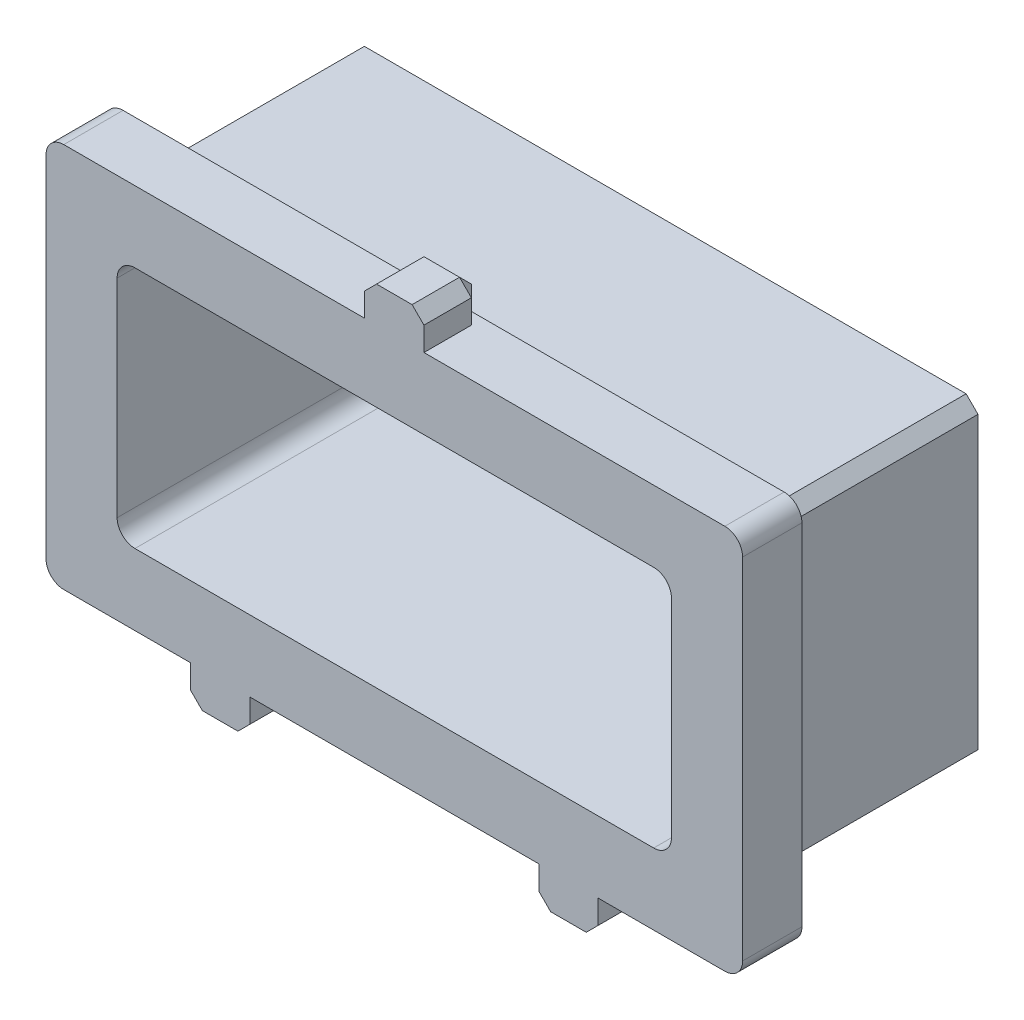
from build123d import *

# Parameters (mm, degrees)
SKETCH1_W           = 13.3985
SKETCH1_H           = 6.731
SKETCH1_W_2         = 11.8745
SKETCH1_H_2         = 5.207
EXTRUDE_THIN1_DEPTH = 5.8039
SKETCH2_W           = 14.9225
SKETCH2_H           = 8.255
SKETCH2_W_2         = 13.3985
SKETCH2_H_2         = 6.731
EXTRUDE_THIN2_DEPTH = 1.27
SKETCH4_W           = 1.27
SKETCH4_H           = 0.762
BOSS_EXTRUDE1_DEPTH = 1.27
CHAMFER1_SIZE       = 0.254
FILLET1_R           = 0.381


with BuildPart() as part:
    # Sketch1 → Extrude-Thin1 (new body)
    with BuildSketch(Plane.XY):
        with Locations((23.121102666, 199.184077883)):
            Rectangle(SKETCH1_W, SKETCH1_H)
        with Locations((23.121102666, 199.184077883)):
            Rectangle(SKETCH1_W_2, SKETCH1_H_2, mode=Mode.SUBTRACT)
    extrude(amount=EXTRUDE_THIN1_DEPTH)

    # Sketch2 → Extrude-Thin2 (add)
    with BuildSketch(Plane.XY.offset(5.8039)):
        with Locations((23.121102666, 199.184077883)):
            Rectangle(SKETCH2_W, SKETCH2_H)
        with Locations((23.121102666, 199.184077883)):
            Rectangle(SKETCH2_W_2, SKETCH2_H_2, mode=Mode.SUBTRACT)
    extrude(amount=-EXTRUDE_THIN2_DEPTH)

    # Sketch4 → Boss-Extrude1 (add)
    with BuildSketch(Plane.XY.offset(5.8039)):
        with Locations((23.121102666, 203.692577883)):
            Rectangle(SKETCH4_W, SKETCH4_H)
        with Locations((26.851727666, 194.675577883)):
            Rectangle(SKETCH4_W, SKETCH4_H)
        with Locations((19.390477666, 194.675577883)):
            Rectangle(SKETCH4_W, SKETCH4_H)
    extrude(amount=-BOSS_EXTRUDE1_DEPTH)

    # Chamfer1
    chamfer1_edges = [part.edges().sort_by_distance(p)[0] for p in [
        (16.421852666, 195.818577883, 2.26695),
        (16.421852666, 202.549577883, 2.26695),
        (29.820352666, 202.549577883, 2.26695),
        (29.820352666, 195.818577883, 2.26695),
        (22.486102666, 203.692577883, 4.5339),
        (23.121102666, 204.073577883, 4.5339),
        (22.486102666, 204.073577883, 5.1689),
        (23.756102666, 203.692577883, 4.5339),
        (23.756102666, 204.073577883, 5.1689),
        (27.486727666, 194.675577883, 4.5339),
        (26.851727666, 194.294577883, 4.5339),
        (27.486727666, 194.294577883, 5.1689),
        (26.216727666, 194.675577883, 4.5339),
        (26.216727666, 194.294577883, 5.1689),
        (20.025477666, 194.675577883, 4.5339),
        (19.390477666, 194.294577883, 4.5339),
        (20.025477666, 194.294577883, 5.1689),
        (18.755477666, 194.675577883, 4.5339),
        (18.755477666, 194.294577883, 5.1689),
    ]]
    chamfer(chamfer1_edges, length=CHAMFER1_SIZE)

    # Fillet1
    fillet1_edges = [part.edges().sort_by_distance(p)[0] for p in [
        (15.659852666, 203.311577883, 5.1689),
        (15.659852666, 195.056577883, 5.1689),
        (30.582352666, 195.056577883, 5.1689),
        (30.582352666, 203.311577883, 5.1689),
        (29.058352666, 201.787577883, 2.90195),
        (17.183852666, 201.787577883, 2.90195),
        (29.058352666, 196.580577883, 2.90195),
        (17.183852666, 196.580577883, 2.90195),
    ]]
    fillet(fillet1_edges, radius=FILLET1_R)


solid = part.part
